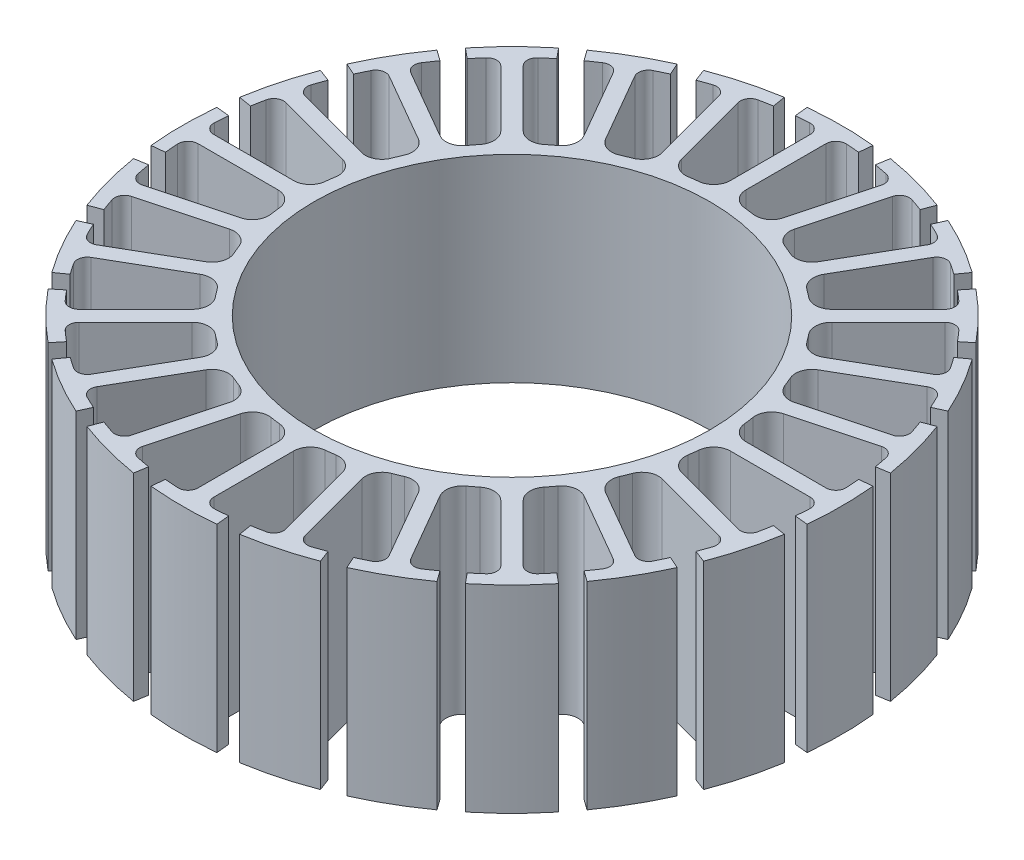
from build123d import *

# Parameters (mm, degrees)
IZIM1_R                     = 15
Y_KSEKLIK_EKSTR_ZYON1_DEPTH = 15


with BuildPart() as part:
    # Çizim1 → Yükseklik-Ekstrüzyon1 (new body)
    with BuildSketch(Plane(origin=(0, 0, 0), x_dir=(1, 0, 0), z_dir=(0, 1, 0))):
        with BuildLine():
            Line((-2.4, 23.879698491), (-2.5, 24.874685928))
            ThreePointArc((-2.5, 24.874685928), (0, 25), (2.5, 24.874685928))
            Line((2.5, 24.874685928), (2.4, 23.879698491))
            ThreePointArc((2.4, 23.879698491), (1.897193909, 23.924896139), (1.393548387, 23.959507985))
            ThreePointArc((1.393548387, 23.959507985), (0.835296828, 23.756282889), (0.6, 23.210773361))
            Line((0.6, 23.210773361), (0.6, 17.150510196))
            ThreePointArc((0.6, 17.150510196), (0.91992676, 16.315367234), (1.715942029, 15.907719603))
            ThreePointArc((1.715942029, 15.907719603), (2.088419076, 15.863117782), (2.459748075, 15.809795679))
            ThreePointArc((2.459748075, 15.809795679), (3.334146752, 15.997529142), (3.859323176, 16.72141216))
            Line((3.859323176, 16.72141216), (5.427834702, 22.575176864))
            ThreePointArc((5.427834702, 22.575176864), (5.341743673, 23.162997906), (4.855112601, 23.503784411))
            ThreePointArc((4.855112601, 23.503784411), (4.359670178, 23.600704988), (3.862298778, 23.687183204))
            Line((3.862298778, 23.687183204), (4.023227893, 24.674149171))
            ThreePointArc((4.023227893, 24.674149171), (6.470476128, 24.148145657), (8.852857025, 23.380053946))
            Line((8.852857025, 23.380053946), (8.498742744, 22.444851788))
            ThreePointArc((8.498742744, 22.444851788), (8.024767368, 22.618645156), (7.547241355, 22.782430685))
            ThreePointArc((7.547241355, 22.782430685), (6.955413232, 22.730616451), (6.586945693, 22.26459401))
            Line((6.586945693, 22.26459401), (5.018434168, 16.410829306))
            ThreePointArc((5.018434168, 16.410829306), (5.111308784, 15.521340011), (5.77469352, 14.921558724))
            ThreePointArc((5.77469352, 14.921558724), (6.122934918, 14.78207252), (6.467810413, 14.634460307))
            ThreePointArc((6.467810413, 14.634460307), (7.361003673, 14.589485877), (8.055639856, 15.152777518))
            Line((8.055639856, 15.152777518), (11.085771438, 20.401119372))
            ThreePointArc((11.085771438, 20.401119372), (11.154753171, 20.991192895), (10.772905688, 21.446316771))
            ThreePointArc((10.772905688, 21.446316771), (10.319429948, 21.668164794), (9.861388276, 21.880425528))
            Line((9.861388276, 21.880425528), (10.272279454, 22.792109925))
            ThreePointArc((10.272279454, 22.792109925), (12.5, 21.650635095), (14.602406473, 20.292109925))
            Line((14.602406473, 20.292109925), (14.018310214, 19.480425528))
            ThreePointArc((14.018310214, 19.480425528), (13.605466191, 19.770970885), (13.186602297, 20.052768384))
            ThreePointArc((13.186602297, 20.052768384), (12.601529717, 20.155896067), (12.125001923, 19.801119372))
            Line((12.125001923, 19.801119372), (9.094870341, 14.552777518))
            ThreePointArc((9.094870341, 14.552777518), (8.954363561, 13.669559117), (9.43990919, 12.918518278))
            ThreePointArc((9.43990919, 12.918518278), (9.740182864, 12.693653445), (10.035102159, 12.461810649))
            ThreePointArc((10.035102159, 12.461810649), (10.886220358, 12.187193259), (11.702977992, 12.551506129))
            Line((11.702977992, 12.551506129), (15.988231171, 16.836759309))
            ThreePointArc((15.988231171, 16.836759309), (16.207584675, 17.388872778), (15.956543056, 17.927318085))
            ThreePointArc((15.956543056, 17.927318085), (15.575937621, 18.258974978), (15.188440461, 18.58255301))
            Line((15.188440461, 18.58255301), (15.821292146, 19.356826052))
            ThreePointArc((15.821292146, 19.356826052), (17.67766953, 17.67766953), (19.356826052, 15.821292146))
            Line((19.356826052, 15.821292146), (18.58255301, 15.188440461))
            ThreePointArc((18.58255301, 15.188440461), (18.258974978, 15.575937621), (17.927318085, 15.956543056))
            ThreePointArc((17.927318085, 15.956543056), (17.388872778, 16.207584675), (16.836759309, 15.988231171))
            Line((16.836759309, 15.988231171), (12.551506129, 11.702977992))
            ThreePointArc((12.551506129, 11.702977992), (12.187193259, 10.886220358), (12.461810649, 10.035102159))
            ThreePointArc((12.461810649, 10.035102159), (12.693653445, 9.740182864), (12.918518278, 9.43990919))
            ThreePointArc((12.918518278, 9.43990919), (13.669559117, 8.954363561), (14.552777518, 9.094870341))
            Line((14.552777518, 9.094870341), (19.801119372, 12.125001923))
            ThreePointArc((19.801119372, 12.125001923), (20.155896067, 12.601529717), (20.052768384, 13.186602297))
            ThreePointArc((20.052768384, 13.186602297), (19.770970885, 13.605466191), (19.480425528, 14.018310214))
            Line((19.480425528, 14.018310214), (20.292109925, 14.602406473))
            ThreePointArc((20.292109925, 14.602406473), (21.650635095, 12.5), (22.792109925, 10.272279454))
            Line((22.792109925, 10.272279454), (21.880425528, 9.861388276))
            ThreePointArc((21.880425528, 9.861388276), (21.668164794, 10.319429948), (21.446316771, 10.772905688))
            ThreePointArc((21.446316771, 10.772905688), (20.991192895, 11.154753171), (20.401119372, 11.085771438))
            Line((20.401119372, 11.085771438), (15.152777518, 8.055639856))
            ThreePointArc((15.152777518, 8.055639856), (14.589485877, 7.361003673), (14.634460307, 6.467810413))
            ThreePointArc((14.634460307, 6.467810413), (14.78207252, 6.122934918), (14.921558724, 5.77469352))
            ThreePointArc((14.921558724, 5.77469352), (15.521340011, 5.111308784), (16.410829306, 5.018434168))
            Line((16.410829306, 5.018434168), (22.26459401, 6.586945693))
            ThreePointArc((22.26459401, 6.586945693), (22.730616451, 6.955413232), (22.782430685, 7.547241355))
            ThreePointArc((22.782430685, 7.547241355), (22.618645156, 8.024767368), (22.444851788, 8.498742744))
            Line((22.444851788, 8.498742744), (23.380053946, 8.852857025))
            ThreePointArc((23.380053946, 8.852857025), (24.148145657, 6.470476128), (24.674149171, 4.023227893))
            Line((24.674149171, 4.023227893), (23.687183204, 3.862298778))
            ThreePointArc((23.687183204, 3.862298778), (23.600704988, 4.359670178), (23.503784411, 4.855112601))
            ThreePointArc((23.503784411, 4.855112601), (23.162997906, 5.341743673), (22.575176864, 5.427834702))
            Line((22.575176864, 5.427834702), (16.72141216, 3.859323176))
            ThreePointArc((16.72141216, 3.859323176), (15.997529142, 3.334146752), (15.809795679, 2.459748075))
            ThreePointArc((15.809795679, 2.459748075), (15.863117782, 2.088419076), (15.907719603, 1.715942029))
            ThreePointArc((15.907719603, 1.715942029), (16.315367234, 0.91992676), (17.150510196, 0.6))
            Line((17.150510196, 0.6), (23.210773361, 0.6))
            ThreePointArc((23.210773361, 0.6), (23.756282889, 0.835296828), (23.959507985, 1.393548387))
            ThreePointArc((23.959507985, 1.393548387), (23.924896139, 1.897193909), (23.879698491, 2.4))
            Line((23.879698491, 2.4), (24.874685928, 2.5))
            ThreePointArc((24.874685928, 2.5), (25, 0), (24.874685928, -2.5))
            Line((24.874685928, -2.5), (23.879698491, -2.4))
            ThreePointArc((23.879698491, -2.4), (23.924896139, -1.897193909), (23.959507985, -1.393548387))
            ThreePointArc((23.959507985, -1.393548387), (23.756282889, -0.835296828), (23.210773361, -0.6))
            Line((23.210773361, -0.6), (17.150510196, -0.6))
            ThreePointArc((17.150510196, -0.6), (16.315367234, -0.91992676), (15.907719603, -1.715942029))
            ThreePointArc((15.907719603, -1.715942029), (15.863117782, -2.088419076), (15.809795679, -2.459748075))
            ThreePointArc((15.809795679, -2.459748075), (15.997529142, -3.334146752), (16.72141216, -3.859323176))
            Line((16.72141216, -3.859323176), (22.575176864, -5.427834702))
            ThreePointArc((22.575176864, -5.427834702), (23.162997906, -5.341743673), (23.503784411, -4.855112601))
            ThreePointArc((23.503784411, -4.855112601), (23.600704988, -4.359670178), (23.687183204, -3.862298778))
            Line((23.687183204, -3.862298778), (24.674149171, -4.023227893))
            ThreePointArc((24.674149171, -4.023227893), (24.148145657, -6.470476128), (23.380053946, -8.852857025))
            Line((23.380053946, -8.852857025), (22.444851788, -8.498742744))
            ThreePointArc((22.444851788, -8.498742744), (22.618645156, -8.024767368), (22.782430685, -7.547241355))
            ThreePointArc((22.782430685, -7.547241355), (22.730616451, -6.955413232), (22.26459401, -6.586945693))
            Line((22.26459401, -6.586945693), (16.410829306, -5.018434168))
            ThreePointArc((16.410829306, -5.018434168), (15.521340011, -5.111308784), (14.921558724, -5.77469352))
            ThreePointArc((14.921558724, -5.77469352), (14.78207252, -6.122934918), (14.634460307, -6.467810413))
            ThreePointArc((14.634460307, -6.467810413), (14.589485877, -7.361003673), (15.152777518, -8.055639856))
            Line((15.152777518, -8.055639856), (20.401119372, -11.085771438))
            ThreePointArc((20.401119372, -11.085771438), (20.991192895, -11.154753171), (21.446316771, -10.772905688))
            ThreePointArc((21.446316771, -10.772905688), (21.668164794, -10.319429948), (21.880425528, -9.861388276))
            Line((21.880425528, -9.861388276), (22.792109925, -10.272279454))
            ThreePointArc((22.792109925, -10.272279454), (21.650635095, -12.5), (20.292109925, -14.602406473))
            Line((20.292109925, -14.602406473), (19.480425528, -14.018310214))
            ThreePointArc((19.480425528, -14.018310214), (19.770970885, -13.605466191), (20.052768384, -13.186602297))
            ThreePointArc((20.052768384, -13.186602297), (20.155896067, -12.601529717), (19.801119372, -12.125001923))
            Line((19.801119372, -12.125001923), (14.552777518, -9.094870341))
            ThreePointArc((14.552777518, -9.094870341), (13.669559117, -8.954363561), (12.918518278, -9.43990919))
            ThreePointArc((12.918518278, -9.43990919), (12.693653445, -9.740182864), (12.461810649, -10.035102159))
            ThreePointArc((12.461810649, -10.035102159), (12.187193259, -10.886220358), (12.551506129, -11.702977992))
            Line((12.551506129, -11.702977992), (16.836759309, -15.988231171))
            ThreePointArc((16.836759309, -15.988231171), (17.388872778, -16.207584675), (17.927318085, -15.956543056))
            ThreePointArc((17.927318085, -15.956543056), (18.258974978, -15.575937621), (18.58255301, -15.188440461))
            Line((18.58255301, -15.188440461), (19.356826052, -15.821292146))
            ThreePointArc((19.356826052, -15.821292146), (17.67766953, -17.67766953), (15.821292146, -19.356826052))
            Line((15.821292146, -19.356826052), (15.188440461, -18.58255301))
            ThreePointArc((15.188440461, -18.58255301), (15.575937621, -18.258974978), (15.956543056, -17.927318085))
            ThreePointArc((15.956543056, -17.927318085), (16.207584675, -17.388872778), (15.988231171, -16.836759309))
            Line((15.988231171, -16.836759309), (11.702977992, -12.551506129))
            ThreePointArc((11.702977992, -12.551506129), (10.886220358, -12.187193259), (10.035102159, -12.461810649))
            ThreePointArc((10.035102159, -12.461810649), (9.740182864, -12.693653445), (9.43990919, -12.918518278))
            ThreePointArc((9.43990919, -12.918518278), (8.954363561, -13.669559117), (9.094870341, -14.552777518))
            Line((9.094870341, -14.552777518), (12.125001923, -19.801119372))
            ThreePointArc((12.125001923, -19.801119372), (12.601529717, -20.155896067), (13.186602297, -20.052768384))
            ThreePointArc((13.186602297, -20.052768384), (13.605466191, -19.770970885), (14.018310214, -19.480425528))
            Line((14.018310214, -19.480425528), (14.602406473, -20.292109925))
            ThreePointArc((14.602406473, -20.292109925), (12.5, -21.650635095), (10.272279454, -22.792109925))
            Line((10.272279454, -22.792109925), (9.861388276, -21.880425528))
            ThreePointArc((9.861388276, -21.880425528), (10.319429948, -21.668164794), (10.772905688, -21.446316771))
            ThreePointArc((10.772905688, -21.446316771), (11.154753171, -20.991192895), (11.085771438, -20.401119372))
            Line((11.085771438, -20.401119372), (8.055639856, -15.152777518))
            ThreePointArc((8.055639856, -15.152777518), (7.361003673, -14.589485877), (6.467810413, -14.634460307))
            ThreePointArc((6.467810413, -14.634460307), (6.122934918, -14.78207252), (5.77469352, -14.921558724))
            ThreePointArc((5.77469352, -14.921558724), (5.111308784, -15.521340011), (5.018434168, -16.410829306))
            Line((5.018434168, -16.410829306), (6.586945693, -22.26459401))
            ThreePointArc((6.586945693, -22.26459401), (6.955413232, -22.730616451), (7.547241355, -22.782430685))
            ThreePointArc((7.547241355, -22.782430685), (8.024767368, -22.618645156), (8.498742744, -22.444851788))
            Line((8.498742744, -22.444851788), (8.852857025, -23.380053946))
            ThreePointArc((8.852857025, -23.380053946), (6.470476128, -24.148145657), (4.023227893, -24.674149171))
            Line((4.023227893, -24.674149171), (3.862298778, -23.687183204))
            ThreePointArc((3.862298778, -23.687183204), (4.359670178, -23.600704988), (4.855112601, -23.503784411))
            ThreePointArc((4.855112601, -23.503784411), (5.341743673, -23.162997906), (5.427834702, -22.575176864))
            Line((5.427834702, -22.575176864), (3.859323176, -16.72141216))
            ThreePointArc((3.859323176, -16.72141216), (3.334146752, -15.997529142), (2.459748075, -15.809795679))
            ThreePointArc((2.459748075, -15.809795679), (2.088419076, -15.863117782), (1.715942029, -15.907719603))
            ThreePointArc((1.715942029, -15.907719603), (0.91992676, -16.315367234), (0.6, -17.150510196))
            Line((0.6, -17.150510196), (0.6, -23.210773361))
            ThreePointArc((0.6, -23.210773361), (0.835296828, -23.756282889), (1.393548387, -23.959507985))
            ThreePointArc((1.393548387, -23.959507985), (1.897193909, -23.924896139), (2.4, -23.879698491))
            Line((2.4, -23.879698491), (2.5, -24.874685928))
            ThreePointArc((2.5, -24.874685928), (0, -25), (-2.5, -24.874685928))
            Line((-2.5, -24.874685928), (-2.4, -23.879698491))
            ThreePointArc((-2.4, -23.879698491), (-1.897193909, -23.924896139), (-1.393548387, -23.959507985))
            ThreePointArc((-1.393548387, -23.959507985), (-0.835296828, -23.756282889), (-0.6, -23.210773361))
            Line((-0.6, -23.210773361), (-0.6, -17.150510196))
            ThreePointArc((-0.6, -17.150510196), (-0.91992676, -16.315367234), (-1.715942029, -15.907719603))
            ThreePointArc((-1.715942029, -15.907719603), (-2.088419076, -15.863117782), (-2.459748075, -15.809795679))
            ThreePointArc((-2.459748075, -15.809795679), (-3.334146752, -15.997529142), (-3.859323176, -16.72141216))
            Line((-3.859323176, -16.72141216), (-5.427834702, -22.575176864))
            ThreePointArc((-5.427834702, -22.575176864), (-5.341743673, -23.162997906), (-4.855112601, -23.503784411))
            ThreePointArc((-4.855112601, -23.503784411), (-4.359670178, -23.600704988), (-3.862298778, -23.687183204))
            Line((-3.862298778, -23.687183204), (-4.023227893, -24.674149171))
            ThreePointArc((-4.023227893, -24.674149171), (-6.470476128, -24.148145657), (-8.852857025, -23.380053946))
            Line((-8.852857025, -23.380053946), (-8.498742744, -22.444851788))
            ThreePointArc((-8.498742744, -22.444851788), (-8.024767368, -22.618645156), (-7.547241355, -22.782430685))
            ThreePointArc((-7.547241355, -22.782430685), (-6.955413232, -22.730616451), (-6.586945693, -22.26459401))
            Line((-6.586945693, -22.26459401), (-5.018434168, -16.410829306))
            ThreePointArc((-5.018434168, -16.410829306), (-5.111308784, -15.521340011), (-5.77469352, -14.921558724))
            ThreePointArc((-5.77469352, -14.921558724), (-6.122934918, -14.78207252), (-6.467810413, -14.634460307))
            ThreePointArc((-6.467810413, -14.634460307), (-7.361003673, -14.589485877), (-8.055639856, -15.152777518))
            Line((-8.055639856, -15.152777518), (-11.085771438, -20.401119372))
            ThreePointArc((-11.085771438, -20.401119372), (-11.154753171, -20.991192895), (-10.772905688, -21.446316771))
            ThreePointArc((-10.772905688, -21.446316771), (-10.319429948, -21.668164794), (-9.861388276, -21.880425528))
            Line((-9.861388276, -21.880425528), (-10.272279454, -22.792109925))
            ThreePointArc((-10.272279454, -22.792109925), (-12.5, -21.650635095), (-14.602406473, -20.292109925))
            Line((-14.602406473, -20.292109925), (-14.018310214, -19.480425528))
            ThreePointArc((-14.018310214, -19.480425528), (-13.605466191, -19.770970885), (-13.186602297, -20.052768384))
            ThreePointArc((-13.186602297, -20.052768384), (-12.601529717, -20.155896067), (-12.125001923, -19.801119372))
            Line((-12.125001923, -19.801119372), (-9.094870341, -14.552777518))
            ThreePointArc((-9.094870341, -14.552777518), (-8.954363561, -13.669559117), (-9.43990919, -12.918518278))
            ThreePointArc((-9.43990919, -12.918518278), (-9.740182864, -12.693653445), (-10.035102159, -12.461810649))
            ThreePointArc((-10.035102159, -12.461810649), (-10.886220358, -12.187193259), (-11.702977992, -12.551506129))
            Line((-11.702977992, -12.551506129), (-15.988231171, -16.836759309))
            ThreePointArc((-15.988231171, -16.836759309), (-16.207584675, -17.388872778), (-15.956543056, -17.927318085))
            ThreePointArc((-15.956543056, -17.927318085), (-15.575937621, -18.258974978), (-15.188440461, -18.58255301))
            Line((-15.188440461, -18.58255301), (-15.821292146, -19.356826052))
            ThreePointArc((-15.821292146, -19.356826052), (-17.67766953, -17.67766953), (-19.356826052, -15.821292146))
            Line((-19.356826052, -15.821292146), (-18.58255301, -15.188440461))
            ThreePointArc((-18.58255301, -15.188440461), (-18.258974978, -15.575937621), (-17.927318085, -15.956543056))
            ThreePointArc((-17.927318085, -15.956543056), (-17.388872778, -16.207584675), (-16.836759309, -15.988231171))
            Line((-16.836759309, -15.988231171), (-12.551506129, -11.702977992))
            ThreePointArc((-12.551506129, -11.702977992), (-12.187193259, -10.886220358), (-12.461810649, -10.035102159))
            ThreePointArc((-12.461810649, -10.035102159), (-12.693653445, -9.740182864), (-12.918518278, -9.43990919))
            ThreePointArc((-12.918518278, -9.43990919), (-13.669559117, -8.954363561), (-14.552777518, -9.094870341))
            Line((-14.552777518, -9.094870341), (-19.801119372, -12.125001923))
            ThreePointArc((-19.801119372, -12.125001923), (-20.155896067, -12.601529717), (-20.052768384, -13.186602297))
            ThreePointArc((-20.052768384, -13.186602297), (-19.770970885, -13.605466191), (-19.480425528, -14.018310214))
            Line((-19.480425528, -14.018310214), (-20.292109925, -14.602406473))
            ThreePointArc((-20.292109925, -14.602406473), (-21.650635095, -12.5), (-22.792109925, -10.272279454))
            Line((-22.792109925, -10.272279454), (-21.880425528, -9.861388276))
            ThreePointArc((-21.880425528, -9.861388276), (-21.668164794, -10.319429948), (-21.446316771, -10.772905688))
            ThreePointArc((-21.446316771, -10.772905688), (-20.991192895, -11.154753171), (-20.401119372, -11.085771438))
            Line((-20.401119372, -11.085771438), (-15.152777518, -8.055639856))
            ThreePointArc((-15.152777518, -8.055639856), (-14.589485877, -7.361003673), (-14.634460307, -6.467810413))
            ThreePointArc((-14.634460307, -6.467810413), (-14.78207252, -6.122934918), (-14.921558724, -5.77469352))
            ThreePointArc((-14.921558724, -5.77469352), (-15.521340011, -5.111308784), (-16.410829306, -5.018434168))
            Line((-16.410829306, -5.018434168), (-22.26459401, -6.586945693))
            ThreePointArc((-22.26459401, -6.586945693), (-22.730616451, -6.955413232), (-22.782430685, -7.547241355))
            ThreePointArc((-22.782430685, -7.547241355), (-22.618645156, -8.024767368), (-22.444851788, -8.498742744))
            Line((-22.444851788, -8.498742744), (-23.380053946, -8.852857025))
            ThreePointArc((-23.380053946, -8.852857025), (-24.148145657, -6.470476128), (-24.674149171, -4.023227893))
            Line((-24.674149171, -4.023227893), (-23.687183204, -3.862298778))
            ThreePointArc((-23.687183204, -3.862298778), (-23.600704988, -4.359670178), (-23.503784411, -4.855112601))
            ThreePointArc((-23.503784411, -4.855112601), (-23.162997906, -5.341743673), (-22.575176864, -5.427834702))
            Line((-22.575176864, -5.427834702), (-16.72141216, -3.859323176))
            ThreePointArc((-16.72141216, -3.859323176), (-15.997529142, -3.334146752), (-15.809795679, -2.459748075))
            ThreePointArc((-15.809795679, -2.459748075), (-15.863117782, -2.088419076), (-15.907719603, -1.715942029))
            ThreePointArc((-15.907719603, -1.715942029), (-16.315367234, -0.91992676), (-17.150510196, -0.6))
            Line((-17.150510196, -0.6), (-23.210773361, -0.6))
            ThreePointArc((-23.210773361, -0.6), (-23.756282889, -0.835296828), (-23.959507985, -1.393548387))
            ThreePointArc((-23.959507985, -1.393548387), (-23.924896139, -1.897193909), (-23.879698491, -2.4))
            Line((-23.879698491, -2.4), (-24.874685928, -2.5))
            ThreePointArc((-24.874685928, -2.5), (-25, 0), (-24.874685928, 2.5))
            Line((-24.874685928, 2.5), (-23.879698491, 2.4))
            ThreePointArc((-23.879698491, 2.4), (-23.924896139, 1.897193909), (-23.959507985, 1.393548387))
            ThreePointArc((-23.959507985, 1.393548387), (-23.756282889, 0.835296828), (-23.210773361, 0.6))
            Line((-23.210773361, 0.6), (-17.150510196, 0.6))
            ThreePointArc((-17.150510196, 0.6), (-16.315367234, 0.91992676), (-15.907719603, 1.715942029))
            ThreePointArc((-15.907719603, 1.715942029), (-15.863117782, 2.088419076), (-15.809795679, 2.459748075))
            ThreePointArc((-15.809795679, 2.459748075), (-15.997529142, 3.334146752), (-16.72141216, 3.859323176))
            Line((-16.72141216, 3.859323176), (-22.575176864, 5.427834702))
            ThreePointArc((-22.575176864, 5.427834702), (-23.162997906, 5.341743673), (-23.503784411, 4.855112601))
            ThreePointArc((-23.503784411, 4.855112601), (-23.600704988, 4.359670178), (-23.687183204, 3.862298778))
            Line((-23.687183204, 3.862298778), (-24.674149171, 4.023227893))
            ThreePointArc((-24.674149171, 4.023227893), (-24.148145657, 6.470476128), (-23.380053946, 8.852857025))
            Line((-23.380053946, 8.852857025), (-22.444851788, 8.498742744))
            ThreePointArc((-22.444851788, 8.498742744), (-22.618645156, 8.024767368), (-22.782430685, 7.547241355))
            ThreePointArc((-22.782430685, 7.547241355), (-22.730616451, 6.955413232), (-22.26459401, 6.586945693))
            Line((-22.26459401, 6.586945693), (-16.410829306, 5.018434168))
            ThreePointArc((-16.410829306, 5.018434168), (-15.521340011, 5.111308784), (-14.921558724, 5.77469352))
            ThreePointArc((-14.921558724, 5.77469352), (-14.78207252, 6.122934918), (-14.634460307, 6.467810413))
            ThreePointArc((-14.634460307, 6.467810413), (-14.589485877, 7.361003673), (-15.152777518, 8.055639856))
            Line((-15.152777518, 8.055639856), (-20.401119372, 11.085771438))
            ThreePointArc((-20.401119372, 11.085771438), (-20.991192895, 11.154753171), (-21.446316771, 10.772905688))
            ThreePointArc((-21.446316771, 10.772905688), (-21.668164794, 10.319429948), (-21.880425528, 9.861388276))
            Line((-21.880425528, 9.861388276), (-22.792109925, 10.272279454))
            ThreePointArc((-22.792109925, 10.272279454), (-21.650635095, 12.5), (-20.292109925, 14.602406473))
            Line((-20.292109925, 14.602406473), (-19.480425528, 14.018310214))
            ThreePointArc((-19.480425528, 14.018310214), (-19.770970885, 13.605466191), (-20.052768384, 13.186602297))
            ThreePointArc((-20.052768384, 13.186602297), (-20.155896067, 12.601529717), (-19.801119372, 12.125001923))
            Line((-19.801119372, 12.125001923), (-14.552777518, 9.094870341))
            ThreePointArc((-14.552777518, 9.094870341), (-13.669559117, 8.954363561), (-12.918518278, 9.43990919))
            ThreePointArc((-12.918518278, 9.43990919), (-12.693653445, 9.740182864), (-12.461810649, 10.035102159))
            ThreePointArc((-12.461810649, 10.035102159), (-12.187193259, 10.886220358), (-12.551506129, 11.702977992))
            Line((-12.551506129, 11.702977992), (-16.836759309, 15.988231171))
            ThreePointArc((-16.836759309, 15.988231171), (-17.388872778, 16.207584675), (-17.927318085, 15.956543056))
            ThreePointArc((-17.927318085, 15.956543056), (-18.258974978, 15.575937621), (-18.58255301, 15.188440461))
            Line((-18.58255301, 15.188440461), (-19.356826052, 15.821292146))
            ThreePointArc((-19.356826052, 15.821292146), (-17.67766953, 17.67766953), (-15.821292146, 19.356826052))
            Line((-15.821292146, 19.356826052), (-15.188440461, 18.58255301))
            ThreePointArc((-15.188440461, 18.58255301), (-15.575937621, 18.258974978), (-15.956543056, 17.927318085))
            ThreePointArc((-15.956543056, 17.927318085), (-16.207584675, 17.388872778), (-15.988231171, 16.836759309))
            Line((-15.988231171, 16.836759309), (-11.702977992, 12.551506129))
            ThreePointArc((-11.702977992, 12.551506129), (-10.886220358, 12.187193259), (-10.035102159, 12.461810649))
            ThreePointArc((-10.035102159, 12.461810649), (-9.740182864, 12.693653445), (-9.43990919, 12.918518278))
            ThreePointArc((-9.43990919, 12.918518278), (-8.954363561, 13.669559117), (-9.094870341, 14.552777518))
            Line((-9.094870341, 14.552777518), (-12.125001923, 19.801119372))
            ThreePointArc((-12.125001923, 19.801119372), (-12.601529717, 20.155896067), (-13.186602297, 20.052768384))
            ThreePointArc((-13.186602297, 20.052768384), (-13.605466191, 19.770970885), (-14.018310214, 19.480425528))
            Line((-14.018310214, 19.480425528), (-14.602406473, 20.292109925))
            ThreePointArc((-14.602406473, 20.292109925), (-12.5, 21.650635095), (-10.272279454, 22.792109925))
            Line((-10.272279454, 22.792109925), (-9.861388276, 21.880425528))
            ThreePointArc((-9.861388276, 21.880425528), (-10.319429948, 21.668164794), (-10.772905688, 21.446316771))
            ThreePointArc((-10.772905688, 21.446316771), (-11.154753171, 20.991192895), (-11.085771438, 20.401119372))
            Line((-11.085771438, 20.401119372), (-8.055639856, 15.152777518))
            ThreePointArc((-8.055639856, 15.152777518), (-7.361003673, 14.589485877), (-6.467810413, 14.634460307))
            ThreePointArc((-6.467810413, 14.634460307), (-6.122934918, 14.78207252), (-5.77469352, 14.921558724))
            ThreePointArc((-5.77469352, 14.921558724), (-5.111308784, 15.521340011), (-5.018434168, 16.410829306))
            Line((-5.018434168, 16.410829306), (-6.586945693, 22.26459401))
            ThreePointArc((-6.586945693, 22.26459401), (-6.955413232, 22.730616451), (-7.547241355, 22.782430685))
            ThreePointArc((-7.547241355, 22.782430685), (-8.024767368, 22.618645156), (-8.498742744, 22.444851788))
            Line((-8.498742744, 22.444851788), (-8.852857025, 23.380053946))
            ThreePointArc((-8.852857025, 23.380053946), (-6.470476128, 24.148145657), (-4.023227893, 24.674149171))
            Line((-4.023227893, 24.674149171), (-3.862298778, 23.687183204))
            ThreePointArc((-3.862298778, 23.687183204), (-4.359670178, 23.600704988), (-4.855112601, 23.503784411))
            ThreePointArc((-4.855112601, 23.503784411), (-5.341743673, 23.162997906), (-5.427834702, 22.575176864))
            Line((-5.427834702, 22.575176864), (-3.859323176, 16.72141216))
            ThreePointArc((-3.859323176, 16.72141216), (-3.334146752, 15.997529142), (-2.459748075, 15.809795679))
            ThreePointArc((-2.459748075, 15.809795679), (-2.088419076, 15.863117782), (-1.715942029, 15.907719603))
            ThreePointArc((-1.715942029, 15.907719603), (-0.91992676, 16.315367234), (-0.6, 17.150510196))
            Line((-0.6, 17.150510196), (-0.6, 23.210773361))
            ThreePointArc((-0.6, 23.210773361), (-0.835296828, 23.756282889), (-1.393548387, 23.959507985))
            ThreePointArc((-1.393548387, 23.959507985), (-1.897193909, 23.924896139), (-2.4, 23.879698491))
        make_face()
        Circle(IZIM1_R, mode=Mode.SUBTRACT)
    extrude(amount=Y_KSEKLIK_EKSTR_ZYON1_DEPTH)


solid = part.part
